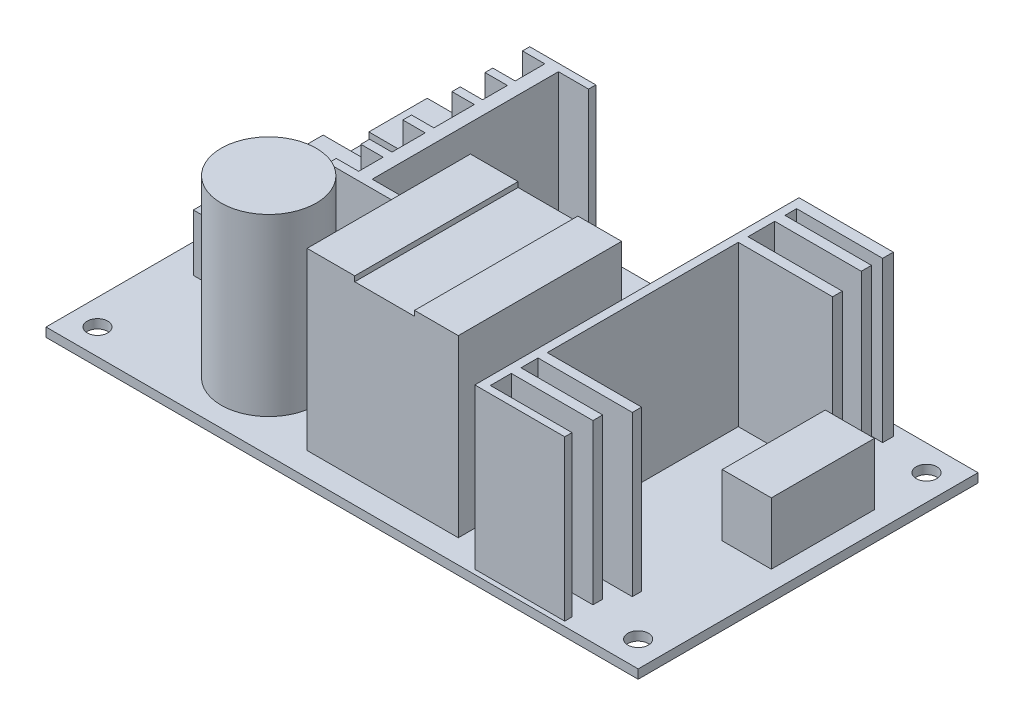
from build123d import *

# Parameters (mm, degrees)
SKETCH1_W           = 115
SKETCH1_H           = 66
BOSS_EXTRUDE1_DEPTH = 1.75
SKETCH2_R           = 2
CUT_EXTRUDE1_DEPTH  = 1.75
SKETCH3_W           = 17.275912382
SKETCH3_H           = 11.328467136
BOSS_EXTRUDE2_DEPTH = 12
SKETCH4_W           = 29.359610659
SKETCH4_H           = 31.719707979
BOSS_EXTRUDE3_DEPTH = 34
SKETCH5_R           = 9.232777937
BOSS_EXTRUDE4_DEPTH = 34
SKETCH6_W           = 9.534793173
SKETCH6_H           = 20.013625273
BOSS_EXTRUDE5_DEPTH = 12
SKETCH7_W           = 18.314355202
SKETCH7_H           = 1.793673963
SKETCH7_W_2         = 1.604866178
SKETCH7_H_2         = 62.967396494
SKETCH7_W_3         = 15.859853989
SKETCH7_H_3         = 1.888077856
SKETCH7_H_4         = 1.416058391
SKETCH7_W_4         = 16.709489025
SKETCH7_H_5         = 2.076885642
SKETCH7_W_5         = 16.803892917
SKETCH7_H_6         = 1.982481748
BOSS_EXTRUDE6_DEPTH = 31
BOSS_EXTRUDE7_DEPTH = 31
SKETCH9_W           = 11.611678814
SKETCH9_H           = 31.719707979
CUT_EXTRUDE2_DEPTH  = 1
SKETCH11_W          = 18.503162988
SKETCH11_H          = 5.097810211
SKETCH11_H_2        = 4.814598532
BOSS_EXTRUDE8_DEPTH = 11


with BuildPart() as part:
    # Sketch1 → Boss-Extrude1 (new body)
    with BuildSketch(Plane(origin=(0, 0, 0), x_dir=(1, 0, 0), z_dir=(0, 1, 0))):
        with Locations((13.127229489, -7.155766944)):
            Rectangle(SKETCH1_W, SKETCH1_H)
    extrude(amount=BOSS_EXTRUDE1_DEPTH)

    # Sketch2 → Cut-Extrude1 (cut)
    with BuildSketch(Plane(origin=(0, 1.75, 0), x_dir=(1, 0, 0), z_dir=(0, 1, 0))):
        with Locations((65.627229489, 20.844233056)):
            Circle(SKETCH2_R)
        with Locations((65.627229489, -35.155766944)):
            Circle(SKETCH2_R)
        with Locations((-39.372770511, 20.844233056)):
            Circle(SKETCH2_R)
        with Locations((-39.372770511, -35.155766944)):
            Circle(SKETCH2_R)
    extrude(amount=-CUT_EXTRUDE1_DEPTH, mode=Mode.SUBTRACT)

    # Sketch3 → Boss-Extrude2 (add)
    with BuildSketch(Plane(origin=(0, 1.75, 0), x_dir=(1, 0, 0), z_dir=(0, 1, 0))):
        with Locations((-25.200750986, 17.672456861)):
            Rectangle(SKETCH3_W, SKETCH3_H)
    extrude(amount=BOSS_EXTRUDE2_DEPTH)

    # Sketch4 → Boss-Extrude3 (add)
    with BuildSketch(Plane(origin=(0, 1.75, 0), x_dir=(1, 0, 0), z_dir=(0, 1, 0))):
        with Locations((16.431365737, -19.711484686)):
            Rectangle(SKETCH4_W, SKETCH4_H)
    extrude(amount=BOSS_EXTRUDE3_DEPTH)

    # Sketch5 → Boss-Extrude4 (add)
    with BuildSketch(Plane(origin=(0, 1.75, 0), x_dir=(1, 0, 0), z_dir=(0, 1, 0))):
        with Locations((-14.202697476, -27.074988324)):
            Circle(SKETCH5_R)
    extrude(amount=BOSS_EXTRUDE4_DEPTH)

    # Sketch6 → Boss-Extrude5 (add)
    with BuildSketch(Plane(origin=(0, 1.75, 0), x_dir=(1, 0, 0), z_dir=(0, 1, 0))):
        with Locations((62.028445957, -0.453090556)):
            Rectangle(SKETCH6_W, SKETCH6_H)
    extrude(amount=BOSS_EXTRUDE5_DEPTH)

    # Sketch7 → Boss-Extrude6 (add)
    with BuildSketch(Plane(origin=(0, 1.75, 0), x_dir=(1, 0, 0), z_dir=(0, 1, 0))):
        with Locations((48.764699019, -27.688613628)):
            Rectangle(SKETCH7_W, SKETCH7_H)
        with Locations((38.805088329, -7.769392247)):
            Rectangle(SKETCH7_W_2, SKETCH7_H_2)
        with Locations((47.537448413, -32.833625784)):
            Rectangle(SKETCH7_W_3, SKETCH7_H_3)
        with Locations((47.537448413, -38.545061299)):
            Rectangle(SKETCH7_W_3, SKETCH7_H_4)
        with Locations((48.764699019, 11.252992151)):
            Rectangle(SKETCH7_W, SKETCH7_H_3)
        with Locations((47.962265931, 22.675863179)):
            Rectangle(SKETCH7_W_4, SKETCH7_H_5)
        with Locations((48.009467877, 18.380486057)):
            Rectangle(SKETCH7_W_5, SKETCH7_H_6)
    extrude(amount=BOSS_EXTRUDE6_DEPTH)

    # Sketch8 → Boss-Extrude7 (add)
    with BuildSketch(Plane(origin=(0, 1.75, 0), x_dir=(1, 0, 0), z_dir=(0, 1, 0))):
        Polygon((-13.541870226, 21.543016466), (-9.197015675, 21.543016466), (-9.197015675, 15.784379005), (-13.541870226, 15.784379005), (-13.541870226, 14.27391672), (-9.197015675, 14.27391672), (-9.197015675, 9.459318188), (-13.541870226, 9.459318188), (-13.541870226, 7.85445201), (-9.197015675, 7.85445201), (-9.197015675, 0), (-13.541870226, 0), (-13.541870226, -1.680341162), (-9.197015675, -1.680341162), (-9.197015675, -8.150462062), (-13.539594744, -8.150462062), (-13.539594744, -9.849732132), (-9.197015675, -9.849732132), (-9.197015675, -14.613674475), (-13.541870226, -14.613674475), (-13.541870226, -16.218540652), (-0.702940806, -16.218540652), (-0.702940806, -14.613674475), (-6.555982159, -14.613674475), (-6.555982159, 21.543016466), (-0.702940806, 21.543016466), (-0.702940806, 22.959074858), (-13.541870226, 22.959074858), align=None)
    extrude(amount=BOSS_EXTRUDE7_DEPTH)

    # Sketch9 → Cut-Extrude2 (cut)
    with BuildSketch(Plane(origin=(0, 35.75, 0), x_dir=(1, 0, 0), z_dir=(0, 1, 0))):
        with Locations((16.808981308, -19.711484686)):
            Rectangle(SKETCH9_W, SKETCH9_H)
    extrude(amount=-CUT_EXTRUDE2_DEPTH, mode=Mode.SUBTRACT)

    # Sketch11 → Boss-Extrude8 (add)
    with BuildSketch(Plane(origin=(0, 1.75, 0), x_dir=(1, 0, 0), z_dir=(0, 1, 0))):
        with Locations((-29.496128108, 5.494354691)):
            Rectangle(SKETCH11_W, SKETCH11_H)
        with Locations((-29.496128108, -14.755280314)):
            Rectangle(SKETCH11_W, SKETCH11_H_2)
    extrude(amount=BOSS_EXTRUDE8_DEPTH)


solid = part.part
